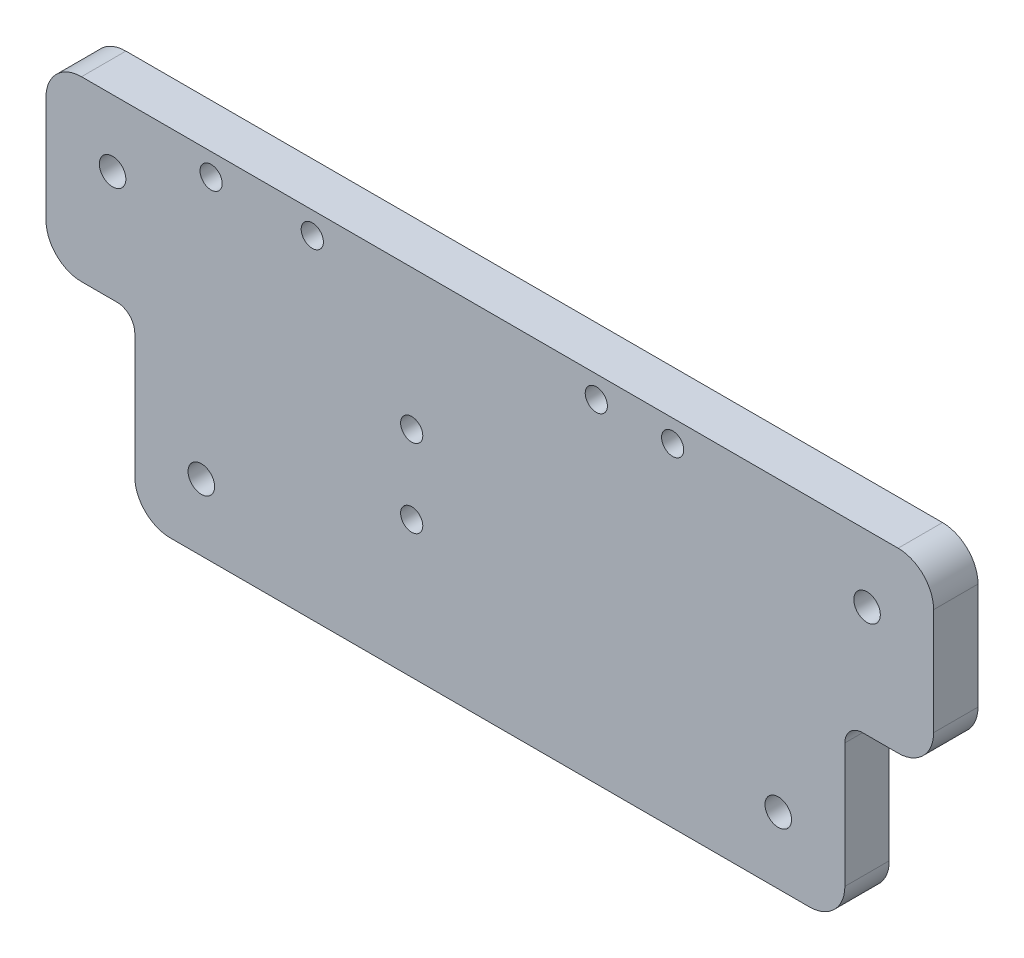
from build123d import *

# Parameters (mm, degrees)
SKETCH1_R           = 1.89865
SKETCH1_R_2         = 1.5875
BOSS_EXTRUDE1_DEPTH = 6.35
FILLET1_R           = 5.08
FILLET2_R           = 2.54


with BuildPart() as part:
    # Sketch1 → Boss-Extrude1 (new body)
    with BuildSketch(Plane.XY):
        Polygon((0, 50.8), (0, 25.4), (12.7, 25.4), (12.7, 0), (114.3, 0), (114.3, 25.4), (127, 25.4), (127, 50.8), align=None)
        with Locations((22.225, 9.525)):
            Circle(SKETCH1_R, mode=Mode.SUBTRACT)
        with Locations((52.324, 19.558)):
            Circle(SKETCH1_R_2, mode=Mode.SUBTRACT)
        with Locations((104.775, 9.525)):
            Circle(SKETCH1_R, mode=Mode.SUBTRACT)
        with Locations((52.324, 30.734)):
            Circle(SKETCH1_R_2, mode=Mode.SUBTRACT)
        with Locations((9.525, 41.275)):
            Circle(SKETCH1_R, mode=Mode.SUBTRACT)
        with Locations((23.622, 47.625)):
            Circle(SKETCH1_R_2, mode=Mode.SUBTRACT)
        with Locations((38.1, 47.625)):
            Circle(SKETCH1_R_2, mode=Mode.SUBTRACT)
        with Locations((78.74, 47.625)):
            Circle(SKETCH1_R_2, mode=Mode.SUBTRACT)
        with Locations((89.662, 47.625)):
            Circle(SKETCH1_R_2, mode=Mode.SUBTRACT)
        with Locations((117.475, 41.275)):
            Circle(SKETCH1_R, mode=Mode.SUBTRACT)
    extrude(amount=BOSS_EXTRUDE1_DEPTH)

    # Fillet1
    fillet1_edges = [part.edges().sort_by_distance(p)[0] for p in [
        (114.3, 0, 3.175),
        (12.7, 0, 3.175),
        (0, 25.4, 3.175),
        (0, 50.8, 3.175),
        (127, 50.8, 3.175),
        (127, 25.4, 3.175),
    ]]
    fillet(fillet1_edges, radius=FILLET1_R)

    # Fillet2
    fillet2_edges = [part.edges().sort_by_distance(p)[0] for p in [
        (12.7, 25.4, 3.175),
        (114.3, 25.4, 3.175),
    ]]
    fillet(fillet2_edges, radius=FILLET2_R)


solid = part.part
